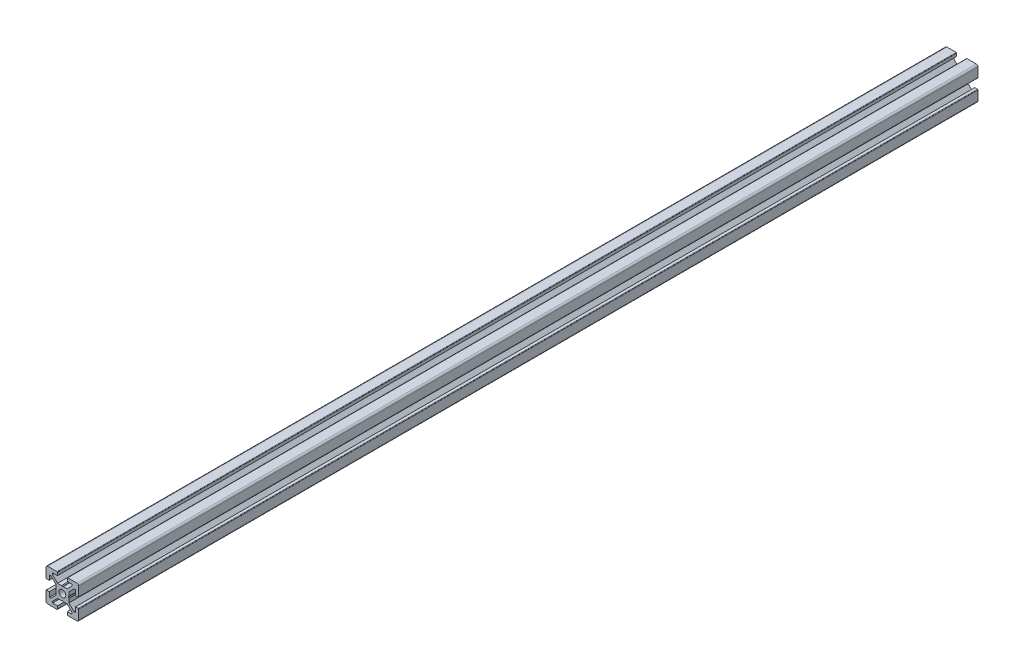
from build123d import *

# Parameters (mm, degrees)
BOSS_EXTRUDE1_DEPTH = 550
SKETCH2_W           = 550.807657805
SKETCH2_H           = 2.1


with BuildPart() as part:
    # Sketch1 → Boss-Extrude1 (new body)
    with BuildSketch(Plane.XY):
        with BuildLine():
            Line((-10, 9), (-10, 3.29999995))
            ThreePointArc((-10, 3.29999995), (-9.912132049, 3.087867916), (-9.7, 3))
            Line((-9.7, 3), (-8, 3))
            Line((-8, 3), (-8, 6))
            Line((-8, 6), (-7.060677, 6))
            Line((-7.060677, 6), (-4, 2.93932965))
            Line((-4, 2.93932965), (-4, 0.519615242))
            Line((-4, 0.519615242), (-3.699996283, -6.437e-06))
            Line((-3.699996283, -6.437e-06), (-4, -0.519628117))
            Line((-4, -0.519628117), (-4, -2.93933725))
            Line((-4, -2.93933725), (-7.0606695, -6))
            Line((-7.0606695, -6), (-8, -6))
            Line((-8, -6), (-8, -3))
            Line((-8, -3), (-9.7, -3))
            ThreePointArc((-9.7, -3), (-9.912132049, -3.087867916), (-10, -3.29999995))
            Line((-10, -3.29999995), (-10, -9))
            ThreePointArc((-10, -9), (-9.707106781, -9.707106781), (-9, -10))
            Line((-9, -10), (-3.29999995, -10))
            ThreePointArc((-3.29999995, -10), (-3.087867916, -9.912132049), (-3, -9.7))
            Line((-3, -9.7), (-3, -8))
            Line((-3, -8), (-6, -8))
            Line((-6, -8), (-6, -7.0606515))
            Line((-6, -7.0606515), (-2.9393489, -4))
            Line((-2.9393489, -4), (-0.519615242, -4))
            Line((-0.519615242, -4), (6.437e-06, -3.699996283))
            Line((6.437e-06, -3.699996283), (0.519628117, -4))
            Line((0.519628117, -4), (2.9393227, -4))
            Line((2.9393227, -4), (6, -7.060677))
            Line((6, -7.060677), (6, -8))
            Line((6, -8), (3, -8))
            Line((3, -8), (3, -9.7))
            ThreePointArc((3, -9.7), (3.087867916, -9.912132049), (3.29999995, -10))
            Line((3.29999995, -10), (9, -10))
            ThreePointArc((9, -10), (9.707106781, -9.707106781), (10, -9))
            Line((10, -9), (10, -3.29999995))
            ThreePointArc((10, -3.29999995), (9.912132049, -3.087867916), (9.7, -3))
            Line((9.7, -3), (8, -3))
            Line((8, -3), (8, -6))
            Line((8, -6), (7.0606435, -6))
            Line((7.0606435, -6), (4, -2.9393482))
            Line((4, -2.9393482), (4, -0.519615242))
            Line((4, -0.519615242), (3.699996283, 6.437e-06))
            Line((3.699996283, 6.437e-06), (4, 0.519628117))
            Line((4, 0.519628117), (4, 2.9393401))
            Line((4, 2.9393401), (7.060651, 6))
            Line((7.060651, 6), (8, 6))
            Line((8, 6), (8, 3))
            Line((8, 3), (9.7, 3))
            ThreePointArc((9.7, 3), (9.912132049, 3.087867916), (10, 3.29999995))
            Line((10, 3.29999995), (10, 9))
            ThreePointArc((10, 9), (9.707106781, 9.707106781), (9, 10))
            Line((9, 10), (3.29999995, 10))
            ThreePointArc((3.29999995, 10), (3.087867916, 9.912132049), (3, 9.7))
            Line((3, 9.7), (3, 8))
            Line((3, 8), (6, 8))
            Line((6, 8), (6, 7.060669))
            Line((6, 7.060669), (2.9393308, 4))
            Line((2.9393308, 4), (0.519615242, 4))
            Line((0.519615242, 4), (-6.437e-06, 3.699996283))
            Line((-6.437e-06, 3.699996283), (-0.519628117, 4))
            Line((-0.519628117, 4), (-2.93935655, 4))
            Line((-2.93935655, 4), (-6, 7.0606435))
            Line((-6, 7.0606435), (-6, 8))
            Line((-6, 8), (-3, 8))
            Line((-3, 8), (-3, 9.7))
            ThreePointArc((-3, 9.7), (-3.087867966, 9.912132034), (-3.3, 10))
            Line((-3.3, 10), (-9, 10))
            ThreePointArc((-9, 10), (-9.707106781, 9.707106781), (-10, 9))
        make_face()
    extrude(amount=-BOSS_EXTRUDE1_DEPTH)

    # Sketch2 → Cut-Revolve1 (revolve, cut)
    with BuildSketch(Plane(origin=(0, 0, 0), x_dir=(0, 0, -1), z_dir=(1, 0, 0))):
        with Locations((274.596171098, 1.05)):
            Rectangle(SKETCH2_W, SKETCH2_H)
    revolve(axis=Axis((0, 0, -550), (0, 0, 1)), mode=Mode.SUBTRACT)


solid = part.part
